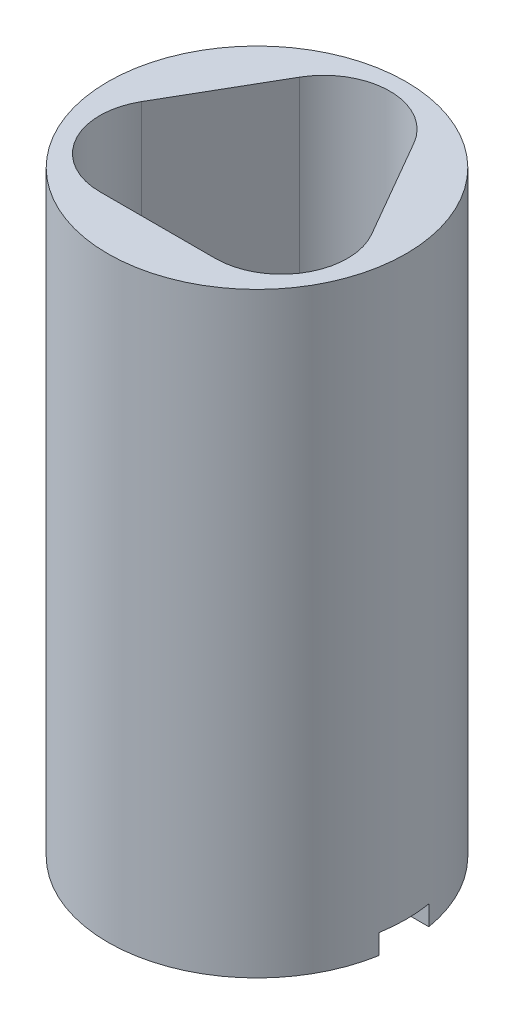
from build123d import *

# Parameters (mm, degrees)
SKETCH1_R                       = 4.7625
EXTRUDE1_DEPTH                  = 19.05
SKETCH2_R                       = 3.0607
CUT_EXTRUDE1_DEPTH              = 10.414
SKETCH3_R                       = 3.4925
CUT_EXTRUDE2_DEPTH              = 0.635
CUT_EXTRUDE5_DEPTH              = 6.35
F_9_64_0_14063_DIAMETER_HOLE1_D = 3.57124
SKETCH7_W                       = 9.525
SKETCH7_H                       = 1.5875
CUT_EXTRUDE4_DEPTH              = 0.635


with BuildPart() as part:
    # Sketch1 → Extrude1 (new body)
    with BuildSketch(Plane(origin=(0, 0, 0), x_dir=(1, 0, 0), z_dir=(0, 1, 0))):
        with Locations(Location((0, 0, 0), (0, 0, 270))):  # turned: the seam where the file's is
            Circle(SKETCH1_R)
    extrude(amount=EXTRUDE1_DEPTH)

    # Sketch2 → Cut-Extrude1 (cut)
    with BuildSketch(Plane(origin=(0, 19.05, 0), x_dir=(1, 0, 0), z_dir=(0, 1, 0))):
        with Locations(Location((0, 0, 0), (0, 0, 270))):  # turned: the seam where the file's is
            Circle(SKETCH2_R)
    extrude(amount=-CUT_EXTRUDE1_DEPTH, mode=Mode.SUBTRACT)

    # Sketch3 → Cut-Extrude2 (cut)
    with BuildSketch(Plane.XZ):
        with Locations(Location((0, 0, 0), (0, 0, 270))):  # turned: the seam where the file's is
            Circle(SKETCH3_R)
    extrude(amount=-CUT_EXTRUDE2_DEPTH, mode=Mode.SUBTRACT)

    # Sketch8 → Cut-Extrude5 (cut)
    with BuildSketch(Plane(origin=(0, 19.05, 0), x_dir=(1, 0, 0), z_dir=(0, 1, 0))):
        with BuildLine():
            Line((-1.825754756, 3.1877), (-3.673506558, -0.0127))
            ThreePointArc((-3.673506558, -0.0127), (-3.673506558, -2.1209), (-1.847751802, -3.175))
            Line((-1.847751802, -3.175), (1.847751802, -3.175))
            ThreePointArc((1.847751802, -3.175), (3.673506558, -2.1209), (3.673506558, -0.0127))
            Line((3.673506558, -0.0127), (1.825754756, 3.1877))
            ThreePointArc((1.825754756, 3.1877), (0, 4.2418), (-1.825754756, 3.1877))
        make_face()
    extrude(amount=-CUT_EXTRUDE5_DEPTH, mode=Mode.SUBTRACT)

    # 9/64 (0.14063) Diameter Hole1 (through all)
    with Locations(Plane(origin=(0, 0.635, 0), x_dir=(0, 0, -1), z_dir=(0, -1, 0))):
        with Locations((0, 0)):
            Hole(F_9_64_0_14063_DIAMETER_HOLE1_D / 2)

    # Sketch7 → Cut-Extrude4 (cut)
    with BuildSketch(Plane.XZ):
        Rectangle(SKETCH7_W, SKETCH7_H)
    extrude(amount=-CUT_EXTRUDE4_DEPTH, mode=Mode.SUBTRACT)


solid = part.part
